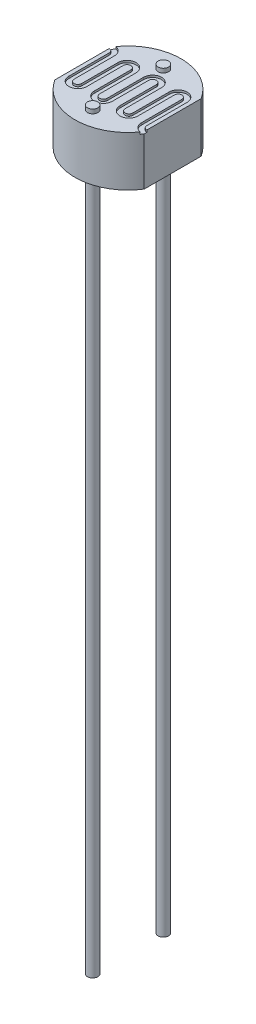
from build123d import *

# Parameters (mm, degrees)
BOSS_EXTRUDE1_DEPTH     = 2.4
BOSS_EXTRUDE2_START     = -2.6
SKETCH2_R               = 0.25
BOSS_EXTRUDE2_DEPTH     = 36.2
CUT_EXTRUDE_THIN1_DEPTH = 0.1


with BuildPart() as part:
    # Sketch1 → Boss-Extrude1 (new body)
    with BuildSketch(Plane(origin=(0, 0, 0), x_dir=(1, 0, 0), z_dir=(0, 1, 0))):
        with BuildLine():
            Line((2.15, 1.37113092), (2.15, -1.37113092))
            ThreePointArc((2.15, -1.37113092), (0, -2.55), (-2.15, -1.37113092))
            Line((-2.15, -1.37113092), (-2.15, 1.37113092))
            ThreePointArc((-2.15, 1.37113092), (0, 2.55), (2.15, 1.37113092))
        make_face()
    extrude(amount=BOSS_EXTRUDE1_DEPTH)

    # Sketch2 → Boss-Extrude2 (add)
    with BuildSketch(Plane.XZ.offset(BOSS_EXTRUDE2_START)):
        with Locations((0, 1.7)):
            Circle(SKETCH2_R)
        with Locations((0, -1.7)):
            Circle(SKETCH2_R)
    extrude(amount=BOSS_EXTRUDE2_DEPTH)

    # Sketch3 → Cut-Extrude-Thin1 (cut)
    with BuildSketch(Plane(origin=(0, 2.4, 0), x_dir=(1, 0, 0), z_dir=(0, 1, 0))):
        with BuildLine():
            ThreePointArc((-2.15, 1.24613092), (-2.021205551, 1.192782512), (-1.967857143, 1.063988063))
            Line((-1.967857143, 1.063988063), (-1.967857143, -0.875))
            ThreePointArc((-1.967857143, -0.875), (-1.535714286, -1.307142857), (-1.103571429, -0.875))
            Line((-1.103571429, -0.875), (-1.103571429, 0.875))
            ThreePointArc((-1.103571429, 0.875), (-0.921428571, 1.057142857), (-0.739285714, 0.875))
            Line((-0.739285714, 0.875), (-0.739285714, -0.875))
            ThreePointArc((-0.739285714, -0.875), (-0.307142857, -1.307142857), (0.125, -0.875))
            Line((0.125, -0.875), (0.125, 0.875))
            ThreePointArc((0.125, 0.875), (0.307142857, 1.057142857), (0.489285714, 0.875))
            Line((0.489285714, 0.875), (0.489285714, -0.875))
            ThreePointArc((0.489285714, -0.875), (0.921428571, -1.307142857), (1.353571429, -0.875))
            Line((1.353571429, -0.875), (1.353571429, 0.875))
            ThreePointArc((1.353571429, 0.875), (1.535714286, 1.057142857), (1.717857143, 0.875))
            Line((1.717857143, 0.875), (1.717857143, -1.063988063))
            ThreePointArc((1.717857143, -1.063988063), (1.844428855, -1.369559208), (2.15, -1.49613092))
            Line((2.15, -1.49613092), (2.15, -1.24613092))
            ThreePointArc((2.15, -1.24613092), (2.021205551, -1.192782512), (1.967857143, -1.063988063))
            Line((1.967857143, -1.063988063), (1.967857143, 0.875))
            ThreePointArc((1.967857143, 0.875), (1.535714286, 1.307142857), (1.103571429, 0.875))
            Line((1.103571429, 0.875), (1.103571429, -0.875))
            ThreePointArc((1.103571429, -0.875), (0.921428571, -1.057142857), (0.739285714, -0.875))
            Line((0.739285714, -0.875), (0.739285714, 0.875))
            ThreePointArc((0.739285714, 0.875), (0.307142857, 1.307142857), (-0.125, 0.875))
            Line((-0.125, 0.875), (-0.125, -0.875))
            ThreePointArc((-0.125, -0.875), (-0.307142857, -1.057142857), (-0.489285714, -0.875))
            Line((-0.489285714, -0.875), (-0.489285714, 0.875))
            ThreePointArc((-0.489285714, 0.875), (-0.921428571, 1.307142857), (-1.353571429, 0.875))
            Line((-1.353571429, 0.875), (-1.353571429, -0.875))
            ThreePointArc((-1.353571429, -0.875), (-1.535714286, -1.057142857), (-1.717857143, -0.875))
            Line((-1.717857143, -0.875), (-1.717857143, 1.063988063))
            ThreePointArc((-1.717857143, 1.063988063), (-1.844428855, 1.369559208), (-2.15, 1.49613092))
            Line((-2.15, 1.49613092), (-2.15, 1.24613092))
        make_face()
    extrude(amount=-CUT_EXTRUDE_THIN1_DEPTH, mode=Mode.SUBTRACT)


solid = part.part
